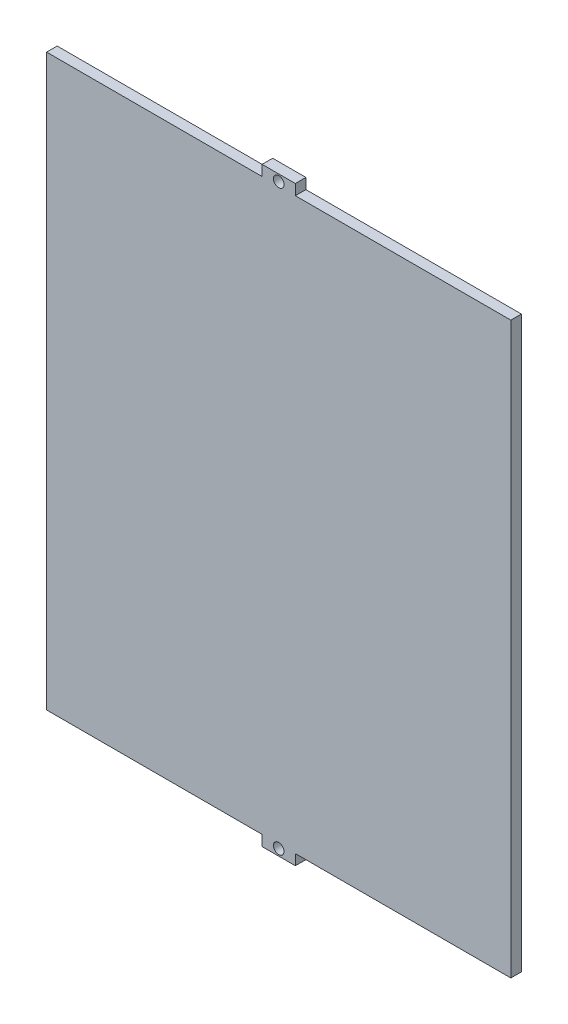
from build123d import *

# Parameters (mm, degrees)
SKETCH1_W           = 139.7
SKETCH1_H           = 177.8
BOSS_EXTRUDE1_DEPTH = 3.18
SKETCH3_R           = 1.59
SKETCH3_W           = 64.85
SKETCH3_H           = 3.18
CUT_EXTRUDE2_DEPTH  = 10


with BuildPart() as part:
    # Sketch1 → Boss-Extrude1 (new body)
    with BuildSketch(Plane.XY):
        Rectangle(SKETCH1_W, SKETCH1_H)
    extrude(amount=BOSS_EXTRUDE1_DEPTH)

    # Sketch3 → Cut-Extrude2 (cut)
    with BuildSketch(Plane.XY.offset(3.18)):
        with Locations((0, -86.9)):
            Circle(SKETCH3_R)
        with Locations((0, 86.9)):
            Circle(SKETCH3_R)
        with Locations((-37.425, -87.31)):
            Rectangle(SKETCH3_W, SKETCH3_H)
        with Locations((37.425, -87.31)):
            Rectangle(SKETCH3_W, SKETCH3_H)
        with Locations((-37.425, 87.31)):
            Rectangle(SKETCH3_W, SKETCH3_H)
        with Locations((37.425, 87.31)):
            Rectangle(SKETCH3_W, SKETCH3_H)
    extrude(amount=-CUT_EXTRUDE2_DEPTH, mode=Mode.SUBTRACT)


solid = part.part
